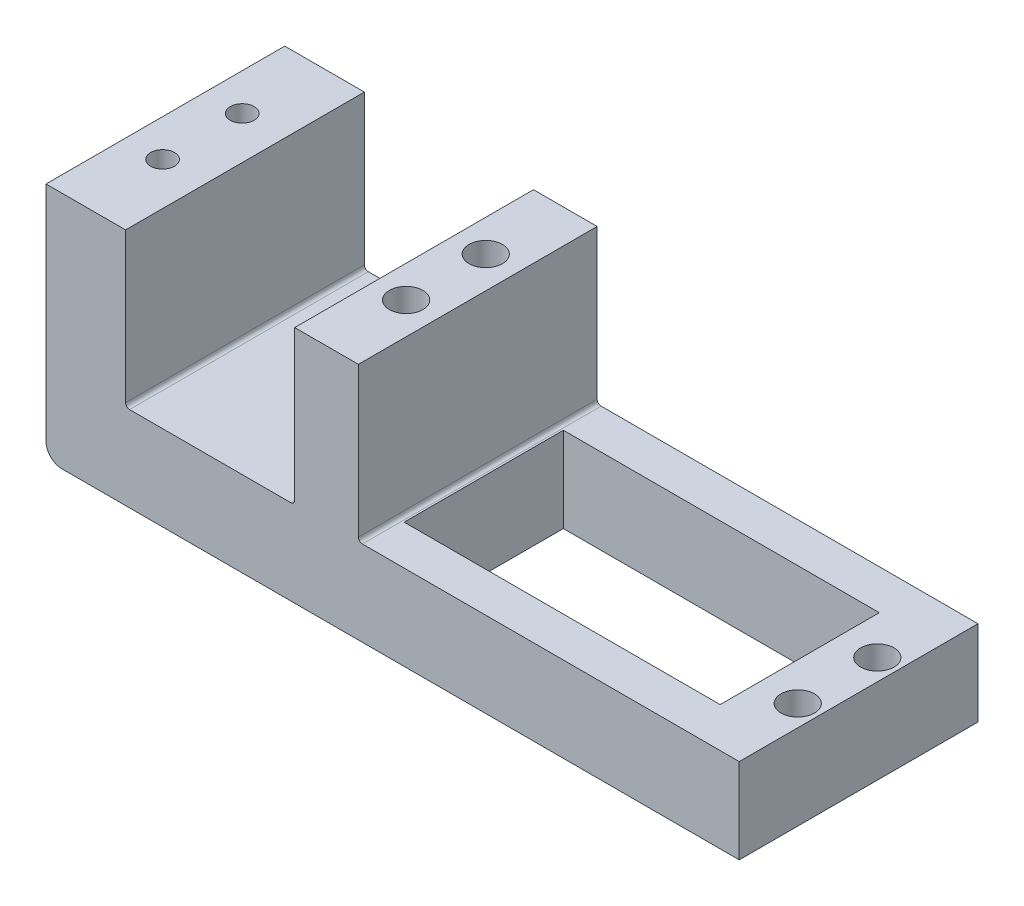
from build123d import *

# Parameters (mm, degrees)
SKETCH1_W           = 77.1
SKETCH1_H           = 30
SKETCH1_W_2         = 39.7
SKETCH1_H_2         = 20
BOSS_EXTRUDE1_DEPTH = 10.7
SKETCH4_W           = 30
SKETCH4_H           = 30
BOSS_EXTRUDE3_DEPTH = 10
CUT_EXTRUDE2_REACH  = 62.083
SKETCH6_R           = 2.1
FILLET5_R           = 2
FILLET6_R           = 0.5
CUT_EXTRUDE3_REACH  = 62.083
SKETCH7_R           = 1.5
SKETCH9_W           = 8
SKETCH9_H           = 30
SKETCH9_R           = 2.1
BOSS_EXTRUDE4_DEPTH = 19.3
FILLET7_R           = 0.5


with BuildPart() as part:
    # Sketch1 → Boss-Extrude1 (new body)
    with BuildSketch(Plane(origin=(0, 0, 0), x_dir=(1, 0, 0), z_dir=(0, 1, 0))):
        with Locations((11.3, 0)):
            Rectangle(SKETCH1_W, SKETCH1_H)
        with Locations((22.6, 0)):
            Rectangle(SKETCH1_W_2, SKETCH1_H_2, mode=Mode.SUBTRACT)
    extrude(amount=BOSS_EXTRUDE1_DEPTH)

    # Sketch4 → Boss-Extrude3 (add)
    with BuildSketch(Plane.ZY.offset(27.25)):
        with Locations((0, 15)):
            Rectangle(SKETCH4_W, SKETCH4_H)
    extrude(amount=BOSS_EXTRUDE3_DEPTH)

    # Sketch6 → Cut-Extrude2 (cut, up to next)
    with BuildSketch(Plane(origin=(0, 0, 0), x_dir=(-1, 0, 0), z_dir=(0, -1, 0)), mode=Mode.PRIVATE) as cut_extrude2_sk1:
        with Locations(Location((2, 5, 0), (0, 0, 90))):
            Circle(SKETCH6_R)
    cut_extrude2_tool1 = extrude(cut_extrude2_sk1.sketch, amount=-CUT_EXTRUDE2_REACH, mode=Mode.PRIVATE) & part.part
    # Sketch6 → Cut-Extrude2 (cut, up to next)
    with BuildSketch(Plane(origin=(0, 0, 0), x_dir=(-1, 0, 0), z_dir=(0, -1, 0)), mode=Mode.PRIVATE) as cut_extrude2_sk2:
        with Locations(Location((2, -5, 0), (0, 0, 90))):
            Circle(SKETCH6_R)
    cut_extrude2_tool2 = extrude(cut_extrude2_sk2.sketch, amount=-CUT_EXTRUDE2_REACH, mode=Mode.PRIVATE) & part.part
    # Sketch6 → Cut-Extrude2 (cut, up to next)
    with BuildSketch(Plane(origin=(0, 0, 0), x_dir=(-1, 0, 0), z_dir=(0, -1, 0)), mode=Mode.PRIVATE) as cut_extrude2_sk3:
        with Locations(Location((-47.2, 5, 0), (0, 0, 90))):
            Circle(SKETCH6_R)
    cut_extrude2_tool3 = extrude(cut_extrude2_sk3.sketch, amount=-CUT_EXTRUDE2_REACH, mode=Mode.PRIVATE) & part.part
    # Sketch6 → Cut-Extrude2 (cut, up to next)
    with BuildSketch(Plane(origin=(0, 0, 0), x_dir=(-1, 0, 0), z_dir=(0, -1, 0)), mode=Mode.PRIVATE) as cut_extrude2_sk4:
        with Locations(Location((-47.2, -5, 0), (0, 0, 90))):
            Circle(SKETCH6_R)
    cut_extrude2_tool4 = extrude(cut_extrude2_sk4.sketch, amount=-CUT_EXTRUDE2_REACH, mode=Mode.PRIVATE) & part.part
    add(cut_extrude2_tool1.solids().sort_by_distance((-2, 0, -5))[0], mode=Mode.SUBTRACT)
    add(cut_extrude2_tool2.solids().sort_by_distance((-2, 0, 5))[0], mode=Mode.SUBTRACT)
    add(cut_extrude2_tool3.solids().sort_by_distance((47.2, 0, -5))[0], mode=Mode.SUBTRACT)
    add(cut_extrude2_tool4.solids().sort_by_distance((47.2, 0, 5))[0], mode=Mode.SUBTRACT)

    # Fillet5
    fillet5_edges = [part.edges().sort_by_distance(p)[0] for p in [
        (-37.25, 0, 0),
    ]]
    fillet(fillet5_edges, radius=FILLET5_R)

    # Fillet6
    fillet6_edges = [part.edges().sort_by_distance(p)[0] for p in [
        (-27.25, 10.7, 0),
    ]]
    fillet(fillet6_edges, radius=FILLET6_R)

    # Sketch7 → Cut-Extrude3 (cut, up to next)
    with BuildSketch(Plane(origin=(0, 0, 0), x_dir=(-1, 0, 0), z_dir=(0, -1, 0)), mode=Mode.PRIVATE) as cut_extrude3_sk1:
        with Locations(Location((32.6, -5, 0), (0, 0, 90))):
            Circle(SKETCH7_R)
    cut_extrude3_tool1 = extrude(cut_extrude3_sk1.sketch, amount=-CUT_EXTRUDE3_REACH, mode=Mode.PRIVATE) & part.part
    # Sketch7 → Cut-Extrude3 (cut, up to next)
    with BuildSketch(Plane(origin=(0, 0, 0), x_dir=(-1, 0, 0), z_dir=(0, -1, 0)), mode=Mode.PRIVATE) as cut_extrude3_sk2:
        with Locations(Location((32.6, 5, 0), (0, 0, 90))):
            Circle(SKETCH7_R)
    cut_extrude3_tool2 = extrude(cut_extrude3_sk2.sketch, amount=-CUT_EXTRUDE3_REACH, mode=Mode.PRIVATE) & part.part
    add(cut_extrude3_tool1.solids().sort_by_distance((-32.6, 0, 5))[0], mode=Mode.SUBTRACT)
    add(cut_extrude3_tool2.solids().sort_by_distance((-32.6, 0, -5))[0], mode=Mode.SUBTRACT)

    # Sketch9 → Boss-Extrude4 (add)
    with BuildSketch(Plane(origin=(0, 10.7, 0), x_dir=(1, 0, 0), z_dir=(0, 1, 0))):
        with Locations((-2, 0)):
            Rectangle(SKETCH9_W, SKETCH9_H)
        with Locations(Location((-2, 5, 0), (0, 0, 90))):
            Circle(SKETCH9_R, mode=Mode.SUBTRACT)
        with Locations(Location((-2, -5, 0), (0, 0, 90))):
            Circle(SKETCH9_R, mode=Mode.SUBTRACT)
    extrude(amount=BOSS_EXTRUDE4_DEPTH)

    # Fillet7
    fillet7_edges = [part.edges().sort_by_distance(p)[0] for p in [
        (-6, 10.7, 0),
        (2, 10.7, 0),
    ]]
    fillet(fillet7_edges, radius=FILLET7_R)


solid = part.part
